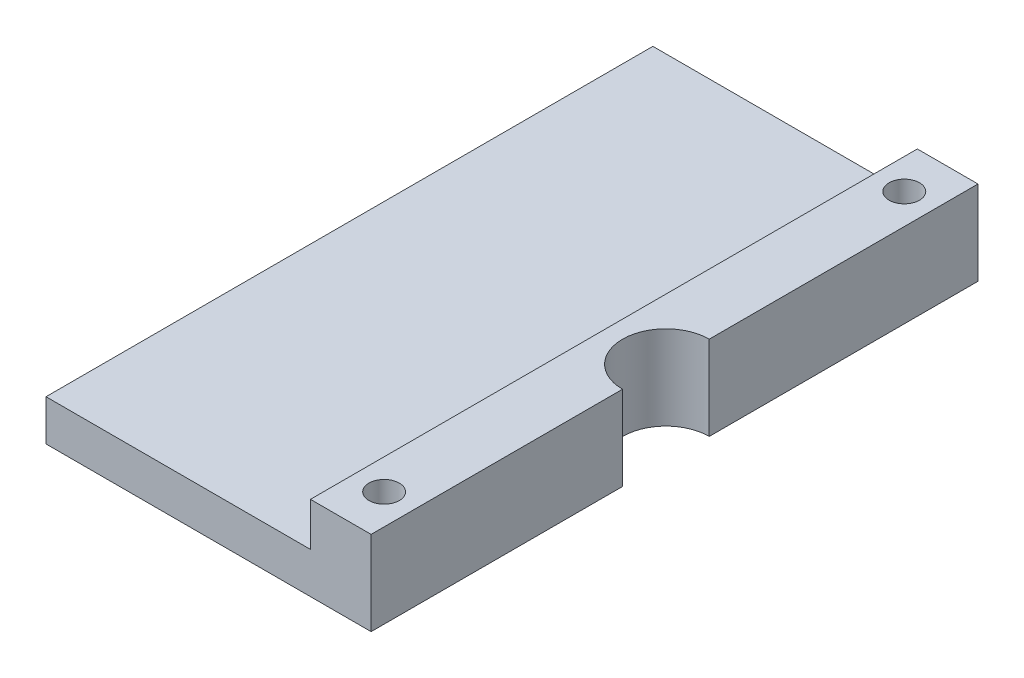
from build123d import *

# Parameters (mm, degrees)
SKETCH1_W               = 41.275
SKETCH1_H               = 88.9
BOSS_EXTRUDE1_DEPTH     = 5.9944
SKETCH1_5_W             = 8.89
SKETCH1_5_H             = 88.9
BOSS_EXTRUDE2_DEPTH     = 12.3444
CUT_EXTRUDE1_DEPTH      = 103.820821998
CUT_EXTRUDE1_DEPTH_BACK = 103.820821998
SKETCH3_R               = 2.2225
SKETCH4_R               = 3.683
CUT_EXTRUDE2_DEPTH      = 4.064
CUT_EXTRUDE3_DEPTH      = 103.274433389
CUT_EXTRUDE3_DEPTH_BACK = 103.274433389
SKETCH5_W               = 2.54
SKETCH5_H               = 88.9
CUT_EXTRUDE4_DEPTH      = 103.820821998
CUT_EXTRUDE4_DEPTH_BACK = 103.820821998
SKETCH6_R               = 6.35


with BuildPart() as part:
    # Sketch1 → Boss-Extrude1 (new body)
    with BuildSketch(Plane(origin=(0, 0, 0), x_dir=(1, 0, 0), z_dir=(0, 1, 0))):
        with Locations((20.6375, 44.45)):
            Rectangle(SKETCH1_W, SKETCH1_H)
    extrude(amount=BOSS_EXTRUDE1_DEPTH)

    # Sketch1_5 → Boss-Extrude2 (add)
    with BuildSketch(Plane(origin=(0, 0, 0), x_dir=(1, 0, 0), z_dir=(0, 1, 0))):
        with Locations((45.72, 44.45)):
            Rectangle(SKETCH1_5_W, SKETCH1_5_H)
    extrude(amount=BOSS_EXTRUDE2_DEPTH)

    # Sketch3 → Cut-Extrude1 (cut, two sides: drawn at the far end of the back side and taken through both)
    with BuildSketch(Plane(origin=(0, 12.3444, 0), x_dir=(1, 0, 0), z_dir=(0, 1, 0)).offset(-CUT_EXTRUDE1_DEPTH_BACK)):
        with Locations((45.72, 82.55)):
            Circle(SKETCH3_R)
        with Locations((45.72, 6.35)):
            Circle(SKETCH3_R)
    extrude(amount=CUT_EXTRUDE1_DEPTH + CUT_EXTRUDE1_DEPTH_BACK, mode=Mode.SUBTRACT)

    # Sketch4 → Cut-Extrude2 (cut)
    with BuildSketch(Plane.XZ):
        with Locations((45.72, -6.35)):
            Circle(SKETCH4_R)
        with Locations((45.72, -82.55)):
            Circle(SKETCH4_R)
    extrude(amount=-CUT_EXTRUDE2_DEPTH, mode=Mode.SUBTRACT)

    # Sketch5 → Cut-Extrude3 (cut, two sides: drawn at the far end of the back side and taken through both)
    with BuildSketch(Plane(origin=(0, 5.9944, 0), x_dir=(1, 0, 0), z_dir=(0, 1, 0)).offset(-CUT_EXTRUDE3_DEPTH_BACK)):
        with Locations((1.27, 44.45)):
            Rectangle(SKETCH5_W, SKETCH5_H)
    extrude(amount=CUT_EXTRUDE3_DEPTH + CUT_EXTRUDE3_DEPTH_BACK, mode=Mode.SUBTRACT)

    # Sketch6 → Cut-Extrude4 (cut, two sides: drawn at the far end of the back side and taken through both)
    with BuildSketch(Plane(origin=(0, 12.3444, 0), x_dir=(1, 0, 0), z_dir=(0, 1, 0)).offset(-CUT_EXTRUDE4_DEPTH_BACK)):
        with Locations((50.165, 43.18)):
            Circle(SKETCH6_R)
    extrude(amount=CUT_EXTRUDE4_DEPTH + CUT_EXTRUDE4_DEPTH_BACK, mode=Mode.SUBTRACT)


solid = part.part
